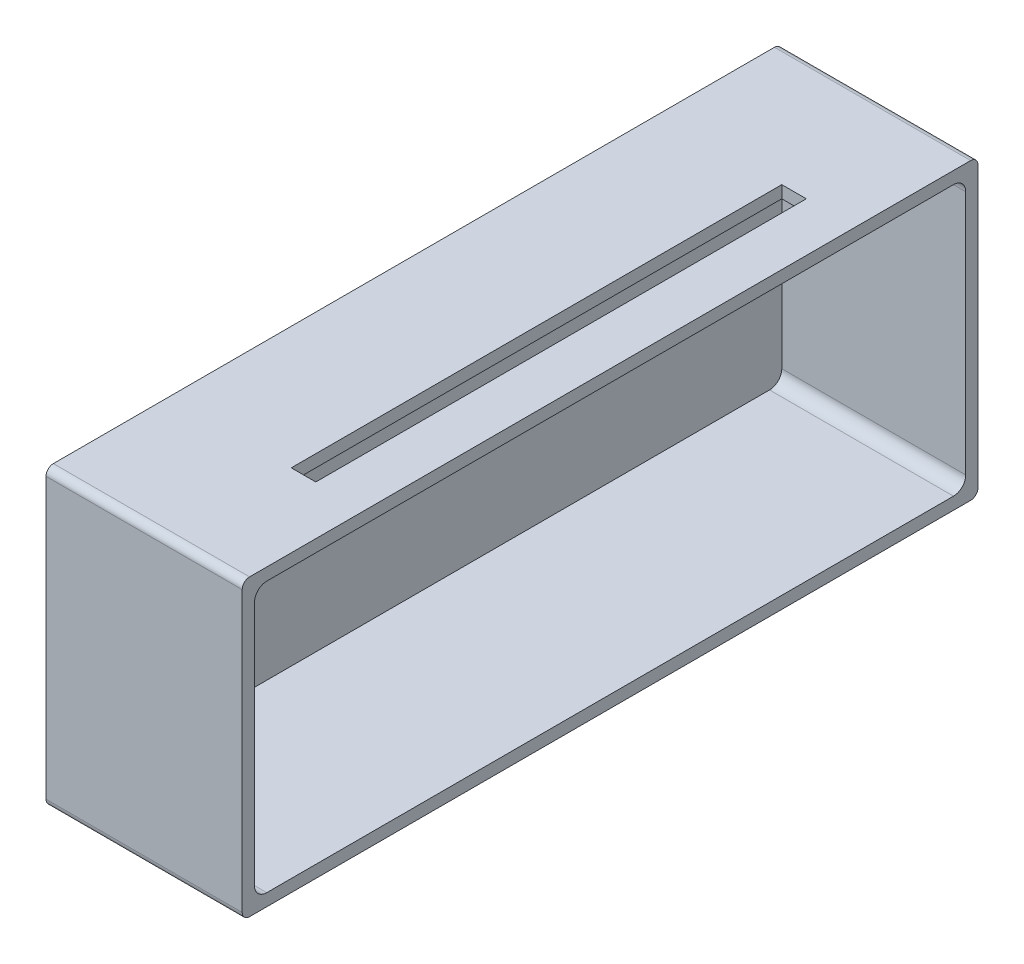
from build123d import *

# Parameters (mm, degrees)
SKETCH_1_W          = 300
SKETCH_1_H          = 120
EXTRUDE_1_DEPTH     = 80
FILLET_1_R          = 3
SHELL_1_T           = -5
FILLET_2_R          = 5
SKETCH_3_W          = 10
SKETCH_3_H          = 200
CUT_EXTRUDE_1_DEPTH = 5


with BuildPart() as part:
    # 草图1 → 凸台-拉伸1 (new body)
    with BuildSketch(Plane(origin=(0, 0, 0), x_dir=(0, 0, -1), z_dir=(1, 0, 0))):
        with Locations((3.008457619, 67.850176247)):
            Rectangle(SKETCH_1_W, SKETCH_1_H)
    extrude(amount=EXTRUDE_1_DEPTH)

    # 圆角1
    fillet_1_edges = [part.edges().sort_by_distance(p)[0] for p in [
        (40, 127.850176247, 146.991542381),
        (40, 127.850176247, -153.008457619),
        (40, 7.850176247, -153.008457619),
        (40, 7.850176247, 146.991542381),
    ]]
    fillet(fillet_1_edges, radius=FILLET_1_R)

    # 抽壳1
    shell_1_openings = [part.faces().sort_by_distance(p)[0] for p in [
        (80, 67.850176247, -3.008457619),
    ]]
    offset(amount=SHELL_1_T, openings=shell_1_openings, kind=Kind.INTERSECTION)

    # 圆角2
    fillet_2_edges = [part.edges().sort_by_distance(p)[0] for p in [
        (42.5, 12.850176247, 141.991542381),
        (42.5, 12.850176247, -148.008457619),
        (42.5, 122.850176247, -148.008457619),
        (42.5, 122.850176247, 141.991542381),
    ]]
    fillet(fillet_2_edges, radius=FILLET_2_R)

    # 草图3 → 切除-拉伸1 (cut)
    with BuildSketch(Plane(origin=(0, 127.850176247, 0), x_dir=(1, 0, 0), z_dir=(0, 1, 0))):
        with Locations((55, 3.008457619)):
            Rectangle(SKETCH_3_W, SKETCH_3_H)
    extrude(amount=-CUT_EXTRUDE_1_DEPTH, mode=Mode.SUBTRACT)


solid = part.part
